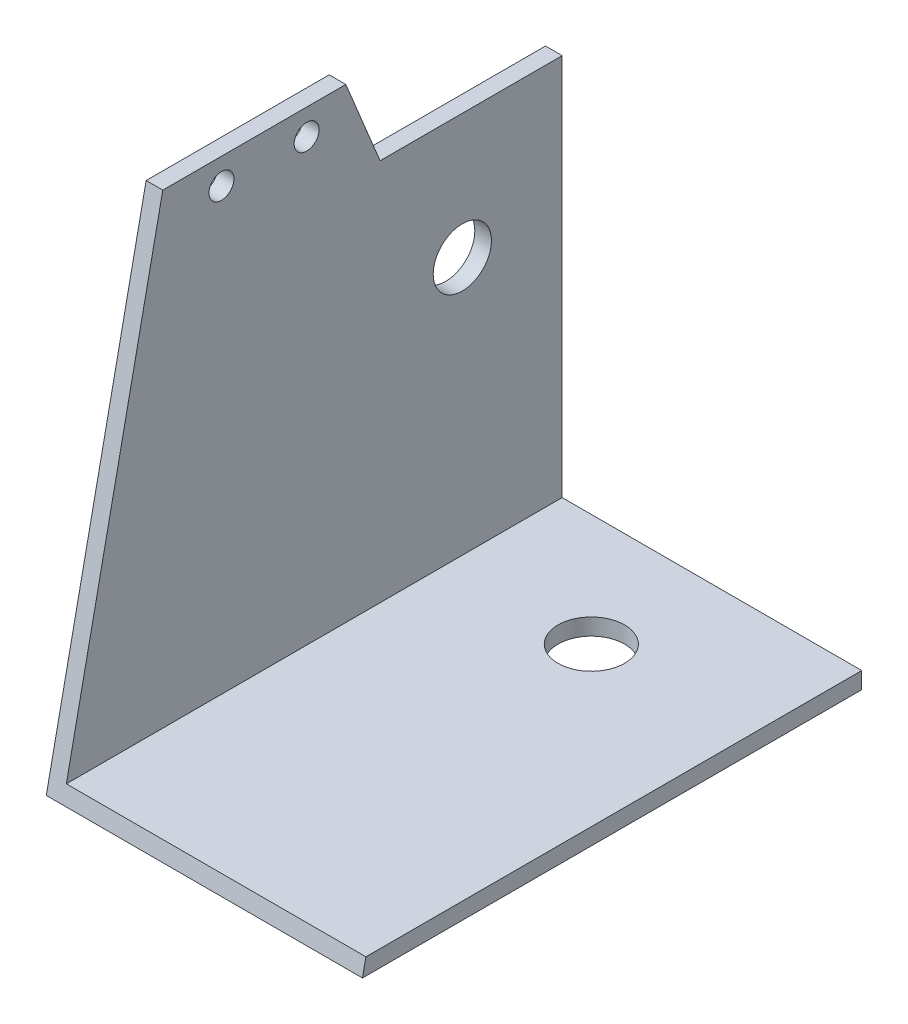
from build123d import *

# Parameters (mm, degrees)
EXTRUDE_1_DEPTH     = 60
SKETCH_2_R          = 1.5
SKETCH_2_R_2        = 3.5
CUT_EXTRUDE_1_DEPTH = 39
SKETCH_3_R          = 4
CUT_EXTRUDE_2_DEPTH = 50


with BuildPart() as part:
    # 草图1 → 凸台-拉伸1 (new body)
    with BuildSketch(Plane.XY):
        Polygon((0, 58), (0, 0), (38, 0), (38, 2), (2, 2), (2, 58), align=None)
    extrude(amount=EXTRUDE_1_DEPTH)

    # 草图2 → 切除-拉伸1 (cut, through all)
    with BuildSketch(Plane.ZY):
        with Locations((30.710851292, 54.912666943)):
            Circle(SKETCH_2_R)
        with Locations((40.948406341, 54.912666943)):
            Circle(SKETCH_2_R)
        with Locations((12, 33)):
            Circle(SKETCH_2_R_2)
        Polygon((60, 0), (60, 58), (48, 58), align=None)
        Polygon((26, 58), (21.884599262, 48), (0, 48), (0, 58), align=None)
    extrude(amount=-CUT_EXTRUDE_1_DEPTH, mode=Mode.SUBTRACT)

    # 草图3 → 切除-拉伸2 (cut)
    with BuildSketch(Plane.XZ):
        with Locations((19, 13.5)):
            Circle(SKETCH_3_R)
    extrude(amount=-CUT_EXTRUDE_2_DEPTH, mode=Mode.SUBTRACT)


solid = part.part
